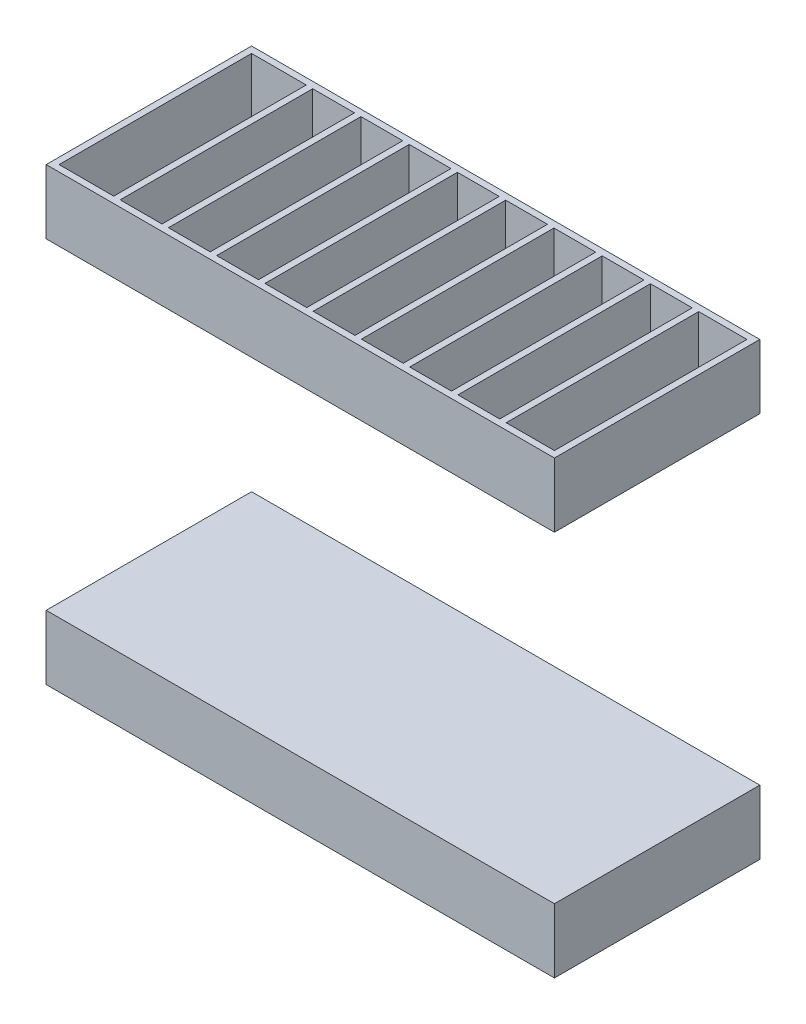
from build123d import *

# Parameters (mm, degrees)
SKETCH2_W        = 1580
SKETCH2_H        = 200
EXTRUDE1_DEPTH   = 638.476
EXTRUDE1_2_DEPTH = 638.476
SHELL1_T         = -20
SHELL2_T         = -20
SKETCH3_W        = 20
SKETCH3_H        = 598.476
EXTRUDE2_DEPTH   = 180
LPATTERN1_COUNT  = 9
LPATTERN1_PITCH  = 150
SKETCH4_W        = 20
SKETCH4_H        = 598.476
EXTRUDE3_DEPTH   = 180
LPATTERN2_COUNT  = 9
LPATTERN2_PITCH  = 150


with BuildPart() as part:
    # Sketch2 → Extrude1 (new body)
    with BuildSketch(Plane.XY):
        with Locations((5792.550750519, 33889.726718834)):
            Rectangle(SKETCH2_W, SKETCH2_H)
    extrude(amount=EXTRUDE1_DEPTH)

    # Shell2
    shell2_openings = [part.faces().sort_by_distance(p)[0] for p in [
        (5792.550750519, 33989.726718834, 319.238),
    ]]
    offset(amount=SHELL2_T, openings=shell2_openings, kind=Kind.INTERSECTION)

    # Sketch4 → Extrude3 (add)
    with BuildSketch(Plane(origin=(0, 33809.726718834, 0), x_dir=(1, 0, 0), z_dir=(0, 1, 0))):
        with Locations((6402.550750519, -319.238)):
            Rectangle(SKETCH4_W, SKETCH4_H)
    extrude3 = extrude(amount=EXTRUDE3_DEPTH)

    # LPattern2: Extrude3 ×9
    with Locations(*[(-i * LPATTERN2_PITCH, 0, 0) for i in range(1, LPATTERN2_COUNT)]):
        add(extrude3)


with BuildPart() as body_2:
    # Sketch2 → Extrude1 2 (new body)
    with BuildSketch(Plane.XY):
        with Locations((5792.550750519, 32689.726718834)):
            Rectangle(SKETCH2_W, SKETCH2_H)
    extrude(amount=EXTRUDE1_2_DEPTH)

    # Shell1
    shell1_openings = [body_2.faces().sort_by_distance(p)[0] for p in [
        (5792.550750519, 32589.726718834, 319.238),
    ]]
    offset(amount=SHELL1_T, openings=shell1_openings, kind=Kind.INTERSECTION)

    # Sketch3 → Extrude2 (add)
    with BuildSketch(Plane(origin=(0, 32769.726718834, 0), x_dir=(1, 0, 0), z_dir=(0, -1, 0))):
        with Locations((5182.550750519, 319.238)):
            Rectangle(SKETCH3_W, SKETCH3_H)
    extrude2 = extrude(amount=EXTRUDE2_DEPTH)

    # LPattern1: Extrude2 ×9
    with Locations(*[(i * LPATTERN1_PITCH, 0, 0) for i in range(1, LPATTERN1_COUNT)]):
        add(extrude2)


solid = Compound([part.part, body_2.part])
